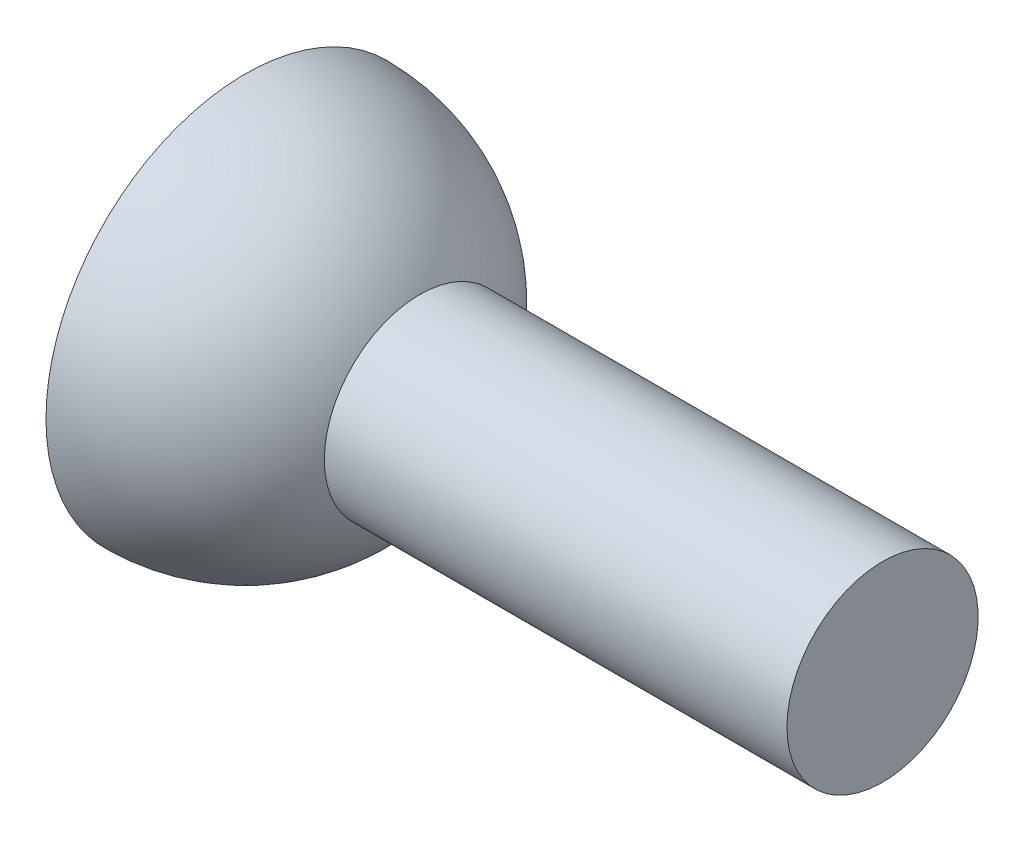
from build123d import *

# Parameters (mm, degrees)
SHELL1_T  = -5
SKETCH3_W = 60
SKETCH3_H = 12


with BuildPart() as part:
    # Sketch2 → Revolve1 (revolve)
    with BuildSketch(Plane(origin=(0, 0, 0), x_dir=(1, 0, 0), z_dir=(0, 1, 0))):
        with BuildLine():
            Line((0, 25), (0, 0))
            Line((0, 0), (25, 0))
            ThreePointArc((25, 0), (17.67766953, 17.67766953), (0, 25))
        make_face()
    revolve(axis=Axis((0, 0, 0), (1, 0, 0)))

    # Shell1
    shell1_openings = [part.faces().sort_by_distance(p)[0] for p in [
        (0, 0, 25),
    ]]
    offset(amount=SHELL1_T, openings=shell1_openings, kind=Kind.INTERSECTION)

    # Sketch3 → Revolve3 (revolve)
    with BuildSketch(Plane.XY):
        with Locations((50, 6)):
            Rectangle(SKETCH3_W, SKETCH3_H)
    revolve(axis=Axis((20, 0, 0), (1, 0, 0)))


solid = part.part
